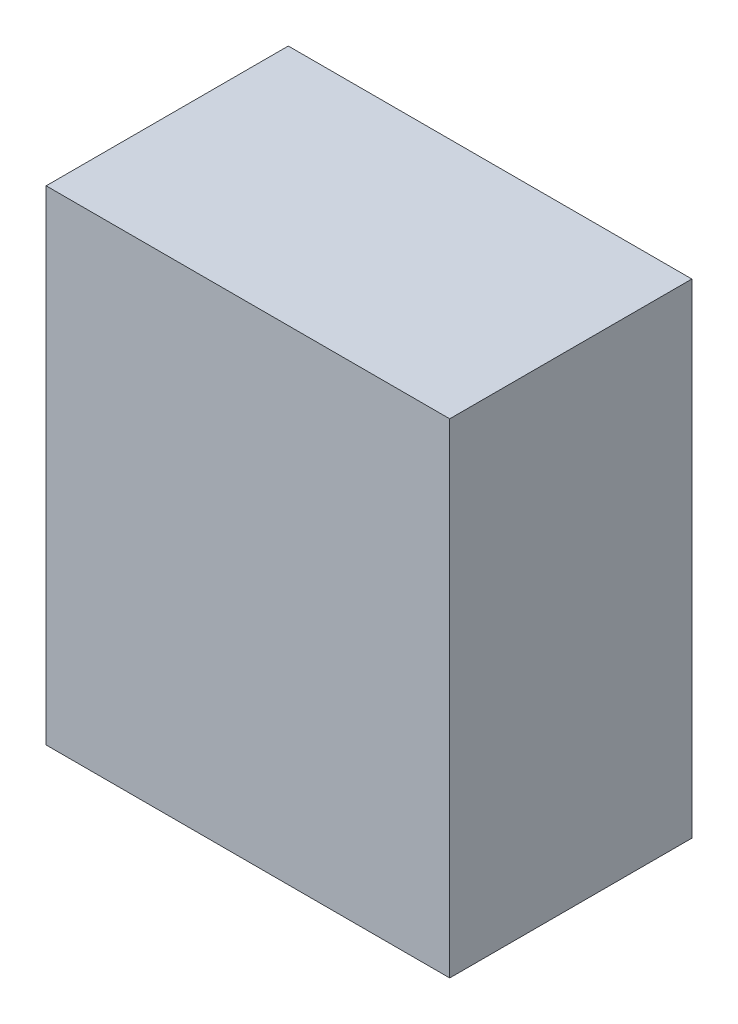
from build123d import *

# Parameters (mm, degrees)
SKETCH1_W           = 250
SKETCH1_H           = 300
BOSS_EXTRUDE1_DEPTH = 150


with BuildPart() as part:
    # Sketch1 → Boss-Extrude1 (new body)
    with BuildSketch(Plane.XY):
        Rectangle(SKETCH1_W, SKETCH1_H)
    extrude(amount=BOSS_EXTRUDE1_DEPTH)


solid = part.part
